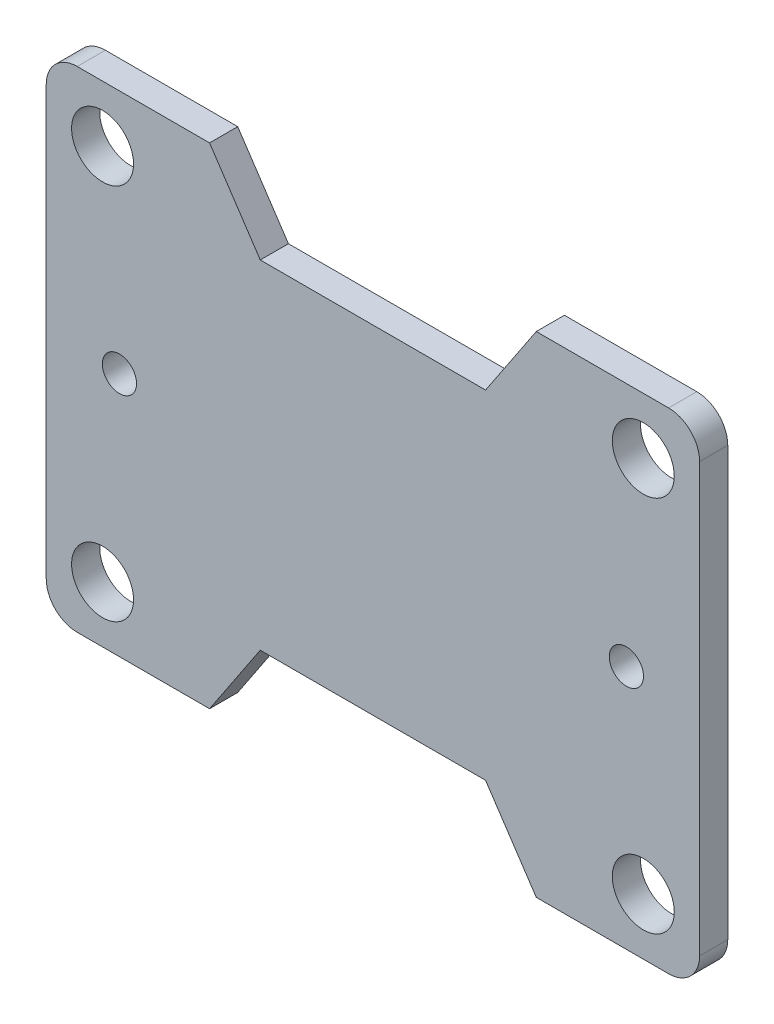
from build123d import *

# Parameters (mm, degrees)
BOSS_EXTRUDE1_DEPTH = 2.5
FILLET1_R           = 2.75


with BuildPart() as part:
    # Sketch1 → Boss-Extrude1 (new body)
    with BuildSketch(Plane.XY):
        with BuildLine():
            ThreePointArc((0, 16.504235885), (-0.014991749, 16.62671172), (-0.02, 16.75))
            Line((-0.02, 16.75), (-5, 16.75))
            Line((-5, 16.75), (-5, -5))
            Line((-5, -5), (9.5, -5))
            Line((9.5, -5), (12.833333333, 0))
            Line((12.833333333, 0), (2.75, 0))
            ThreePointArc((2.75, 0), (1.944543648, -1.944543648), (0, -2.75))
            ThreePointArc((0, -2.75), (-2.75, 0), (0, 2.75))
            Line((0, 2.75), (0, 16.504235885))
        make_face()
        with BuildLine():
            ThreePointArc((0, 30.75), (-2.75, 33.5), (0, 36.25))
            ThreePointArc((0, 36.25), (1.944543648, 35.444543648), (2.75, 33.5))
            Line((2.75, 33.5), (12.833333333, 33.5))
            Line((12.833333333, 33.5), (9.5, 38.5))
            Line((9.5, 38.5), (-5, 38.5))
            Line((-5, 38.5), (-5, 16.75))
            Line((-5, 16.75), (-0.02, 16.75))
            ThreePointArc((-0.02, 16.75), (-0.014991749, 16.87328828), (0, 16.995764115))
            Line((0, 16.995764115), (0, 30.75))
        make_face()
        with BuildLine():
            ThreePointArc((2.75, 33.5), (1.944543648, 31.555456352), (0, 30.75))
            Line((0, 30.75), (0, 16.995764115))
            ThreePointArc((0, 16.995764115), (0.51591704, 17.908438918), (1.5, 18.27))
            ThreePointArc((1.5, 18.27), (2.574802307, 17.824802307), (3.02, 16.75))
            Line((3.02, 16.75), (24, 16.75))
            Line((24, 16.75), (24, 31.75))
            Line((24, 31.75), (14, 31.75))
            Line((14, 31.75), (12.833333333, 33.5))
            Line((12.833333333, 33.5), (2.75, 33.5))
        make_face()
        with BuildLine():
            Line((45.25, 33.5), (35.166666667, 33.5))
            Line((35.166666667, 33.5), (34, 31.75))
            Line((34, 31.75), (24, 31.75))
            Line((24, 31.75), (24, 16.75))
            Line((24, 16.75), (44.98, 16.75))
            ThreePointArc((44.98, 16.75), (45.425197693, 17.824802307), (46.5, 18.27))
            ThreePointArc((46.5, 18.27), (47.48408296, 17.908438918), (48, 16.995764115))
            Line((48, 16.995764115), (48, 30.75))
            ThreePointArc((48, 30.75), (46.055456352, 31.555456352), (45.25, 33.5))
        make_face()
        with BuildLine():
            Line((38.5, 38.5), (35.166666667, 33.5))
            Line((35.166666667, 33.5), (45.25, 33.5))
            ThreePointArc((45.25, 33.5), (46.055456352, 35.444543648), (48, 36.25))
            ThreePointArc((48, 36.25), (49.944543648, 35.444543648), (50.75, 33.5))
            ThreePointArc((50.75, 33.5), (49.944543648, 31.555456352), (48, 30.75))
            Line((48, 30.75), (48, 16.995764115))
            ThreePointArc((48, 16.995764115), (48.014991749, 16.87328828), (48.02, 16.75))
            Line((48.02, 16.75), (53, 16.75))
            Line((53, 16.75), (53, 38.5))
            Line((53, 38.5), (38.5, 38.5))
        make_face()
        with BuildLine():
            ThreePointArc((48.02, 16.75), (48.014991749, 16.62671172), (48, 16.504235885))
            Line((48, 16.504235885), (48, 2.75))
            ThreePointArc((48, 2.75), (49.944543648, 1.944543648), (50.75, 0))
            ThreePointArc((50.75, 0), (49.944543648, -1.944543648), (48, -2.75))
            ThreePointArc((48, -2.75), (46.055456352, -1.944543648), (45.25, 0))
            Line((45.25, 0), (35.166666667, 0))
            Line((35.166666667, 0), (38.5, -5))
            Line((38.5, -5), (53, -5))
            Line((53, -5), (53, 16.75))
            Line((53, 16.75), (48.02, 16.75))
        make_face()
        with BuildLine():
            Line((44.98, 16.75), (24, 16.75))
            Line((24, 16.75), (24, 1.75))
            Line((24, 1.75), (34, 1.75))
            Line((34, 1.75), (35.166666667, 0))
            Line((35.166666667, 0), (45.25, 0))
            ThreePointArc((45.25, 0), (46.055456352, 1.944543648), (48, 2.75))
            Line((48, 2.75), (48, 16.504235885))
            ThreePointArc((48, 16.504235885), (46.37671172, 15.235008251), (44.98, 16.75))
        make_face()
        with BuildLine():
            ThreePointArc((3.02, 16.75), (1.62328828, 15.235008251), (0, 16.504235885))
            Line((0, 16.504235885), (0, 2.75))
            ThreePointArc((0, 2.75), (1.944543648, 1.944543648), (2.75, 0))
            Line((2.75, 0), (12.833333333, 0))
            Line((12.833333333, 0), (14, 1.75))
            Line((14, 1.75), (24, 1.75))
            Line((24, 1.75), (24, 16.75))
            Line((24, 16.75), (3.02, 16.75))
        make_face()
    extrude(amount=BOSS_EXTRUDE1_DEPTH)

    # Fillet1
    fillet1_edges = [part.edges().sort_by_distance(p)[0] for p in [
        (53, -5, 1.25),
        (-5, -5, 1.25),
        (-5, 38.5, 1.25),
        (53, 38.5, 1.25),
    ]]
    fillet(fillet1_edges, radius=FILLET1_R)


solid = part.part
